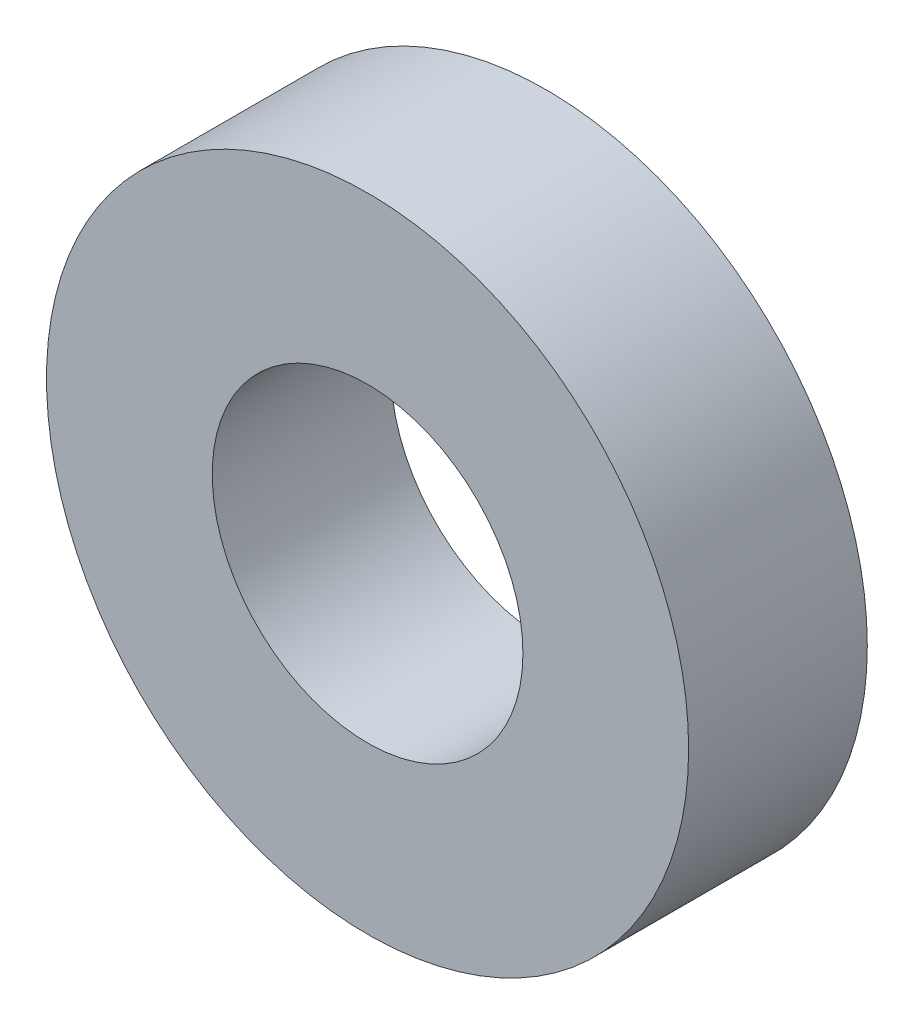
from build123d import *

# Parameters (mm, degrees)
SKETCH_1_W = 17.25
SKETCH_1_H = 16


with BuildPart() as part:
    # 草图1 → 旋转1 (revolve)
    with BuildSketch(Plane(origin=(0, 0, 0), x_dir=(0, 0, -1), z_dir=(1, 0, 0))):
        with Locations((0.526307789, 23)):
            Rectangle(SKETCH_1_W, SKETCH_1_H)
    revolve(axis=Axis((0, 0, 27.368992763), (0, 0, -1)))


solid = part.part
